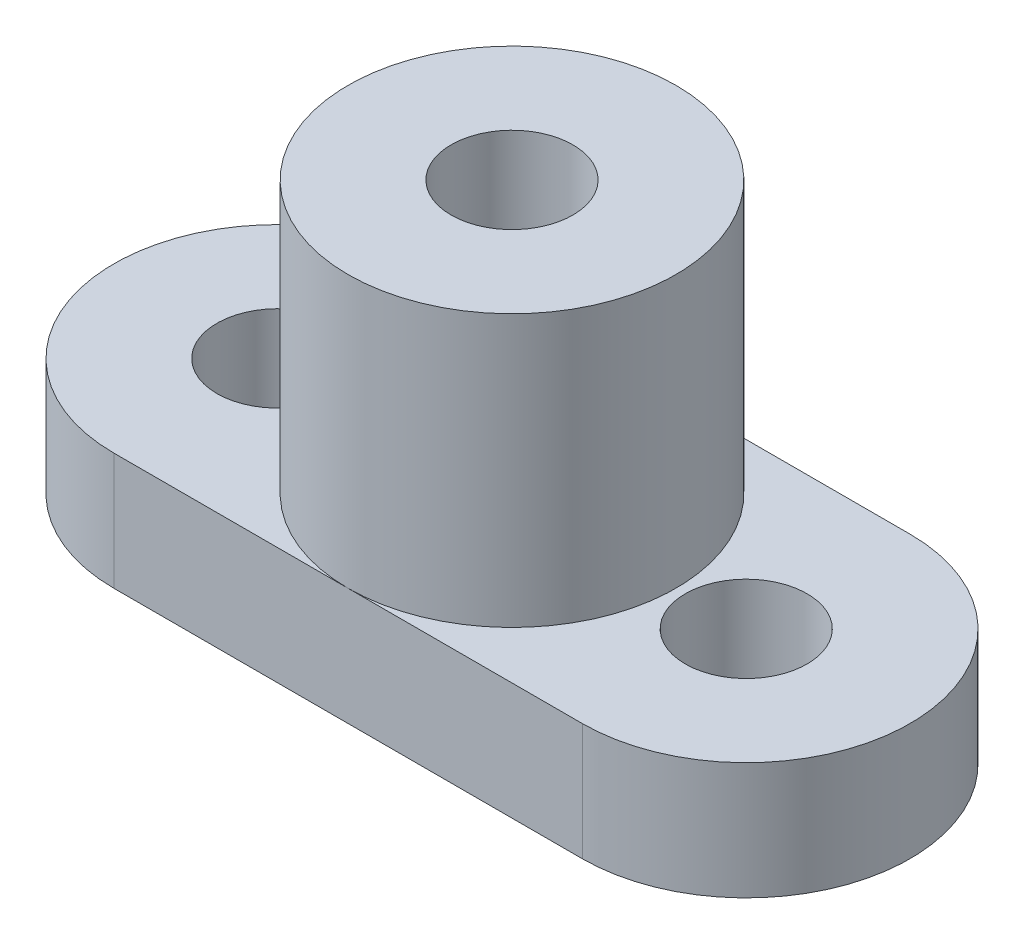
from build123d import *

# Parameters (mm, degrees)
SKETCH1_R           = 1.651
BOSS_EXTRUDE1_DEPTH = 3.175
SKETCH2_R           = 4.445
SKETCH2_R_2         = 1.651
BOSS_EXTRUDE2_DEPTH = 7.366


with BuildPart() as part:
    # Sketch1 → Boss-Extrude1 (new body)
    with BuildSketch(Plane(origin=(0, 0, 0), x_dir=(1, 0, 0), z_dir=(0, 1, 0))):
        with BuildLine():
            Line((0, 4.445), (12.7, 4.445))
            ThreePointArc((12.7, 4.445), (17.145, 0), (12.7, -4.445))
            Line((12.7, -4.445), (0, -4.445))
            ThreePointArc((0, -4.445), (-4.445, 0), (0, 4.445))
        make_face()
        with Locations((12.7, 0)):
            Circle(SKETCH1_R, mode=Mode.SUBTRACT)
        Circle(SKETCH1_R, mode=Mode.SUBTRACT)
    extrude(amount=BOSS_EXTRUDE1_DEPTH)

    # Sketch2 → Boss-Extrude2 (add)
    with BuildSketch(Plane(origin=(0, 3.175, 0), x_dir=(1, 0, 0), z_dir=(0, 1, 0))):
        with Locations((6.35, 0)):
            Circle(SKETCH2_R)
        with Locations((6.35, 0)):
            Circle(SKETCH2_R_2, mode=Mode.SUBTRACT)
    extrude(amount=BOSS_EXTRUDE2_DEPTH)


solid = part.part
